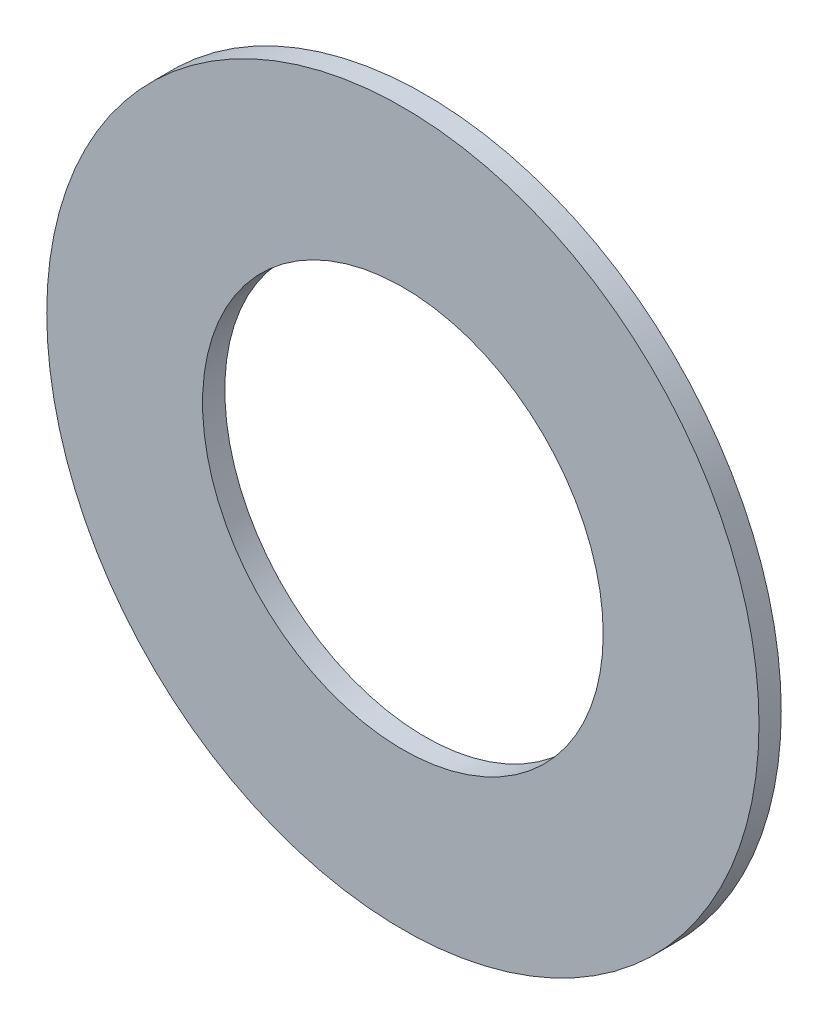
from build123d import *

# Parameters (mm, degrees)
SKETCH1_R           = 8
SKETCH1_R_2         = 4.5
BOSS_EXTRUDE1_DEPTH = 0.5


with BuildPart() as part:
    # Sketch1 → Boss-Extrude1 (new body)
    with BuildSketch(Plane.XY):
        Circle(SKETCH1_R)
        Circle(SKETCH1_R_2, mode=Mode.SUBTRACT)
    extrude(amount=BOSS_EXTRUDE1_DEPTH)


solid = part.part
